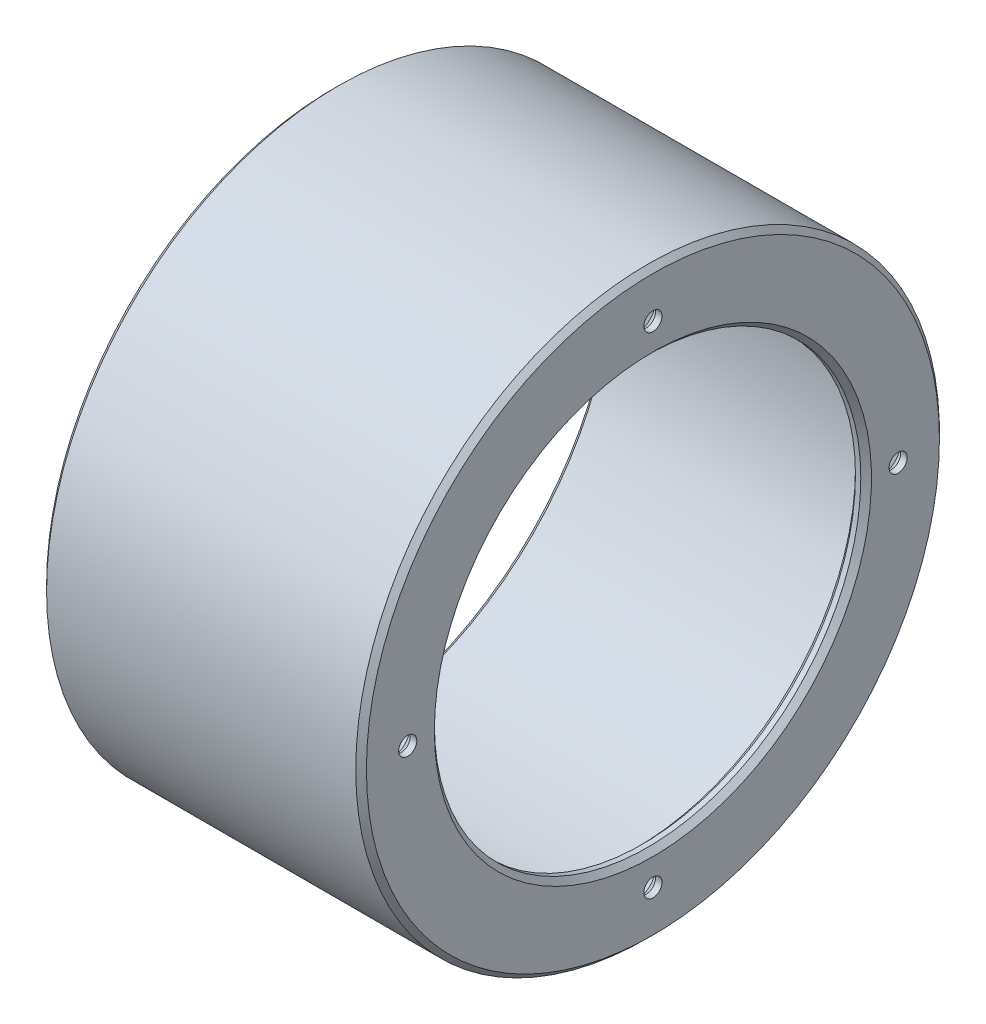
from build123d import *

# Parameters (mm, degrees)
CHAMFER_1_SIZE           = 1
PATTERN_CIRCULAR_2_COUNT = 4


with BuildPart() as part:
    # Эскиз1 → Повернуть1 (revolve)
    with BuildSketch(Plane.XY):
        Polygon((0, 54.75), (60, 54.75), (60, 40), (57, 40), (57, 51.5), (0, 51.5), align=None)
    revolve(axis=Axis((0, 0, 0), (1, 0, 0)))

    # Фаска1
    chamfer_1_edges = [part.edges().sort_by_distance(p)[0] for p in [
        (0, -51.5, 0),
        (57, -40, 0),
        (60, -40, 0),
        (60, -54.75, 0),
        (0, -54.75, 0),
    ]]
    chamfer(chamfer_1_edges, length=CHAMFER_1_SIZE)

    # Эскиз5 → Зенковка для винта с потайной головкой и внутренним шестигранником M31 (revolve, cut)
    with BuildSketch(Plane(origin=(57, 46, 0), x_dir=(0, 0, 1), z_dir=(0, 1, 0))):
        Polygon((0, 0), (0, 22.5), (1.7, 21.478536948), (1.7, 1.77), (3.47, 0), align=None)
    hole_wizard_m31 = revolve(axis=Axis((50.65, 46, 0), (1, 0, 0)), mode=Mode.SUBTRACT)

    # Круговой массив2: Зенковка для винта с потайной головкой и внутренним шестигранником M31 ×4 about axis
    pattern_circular_2_axis = Axis((0, 0, 0), (1, 0, 0))
    for i in range(1, PATTERN_CIRCULAR_2_COUNT):
        add(hole_wizard_m31.rotate(pattern_circular_2_axis, i * 360 / PATTERN_CIRCULAR_2_COUNT), mode=Mode.SUBTRACT)


solid = part.part
